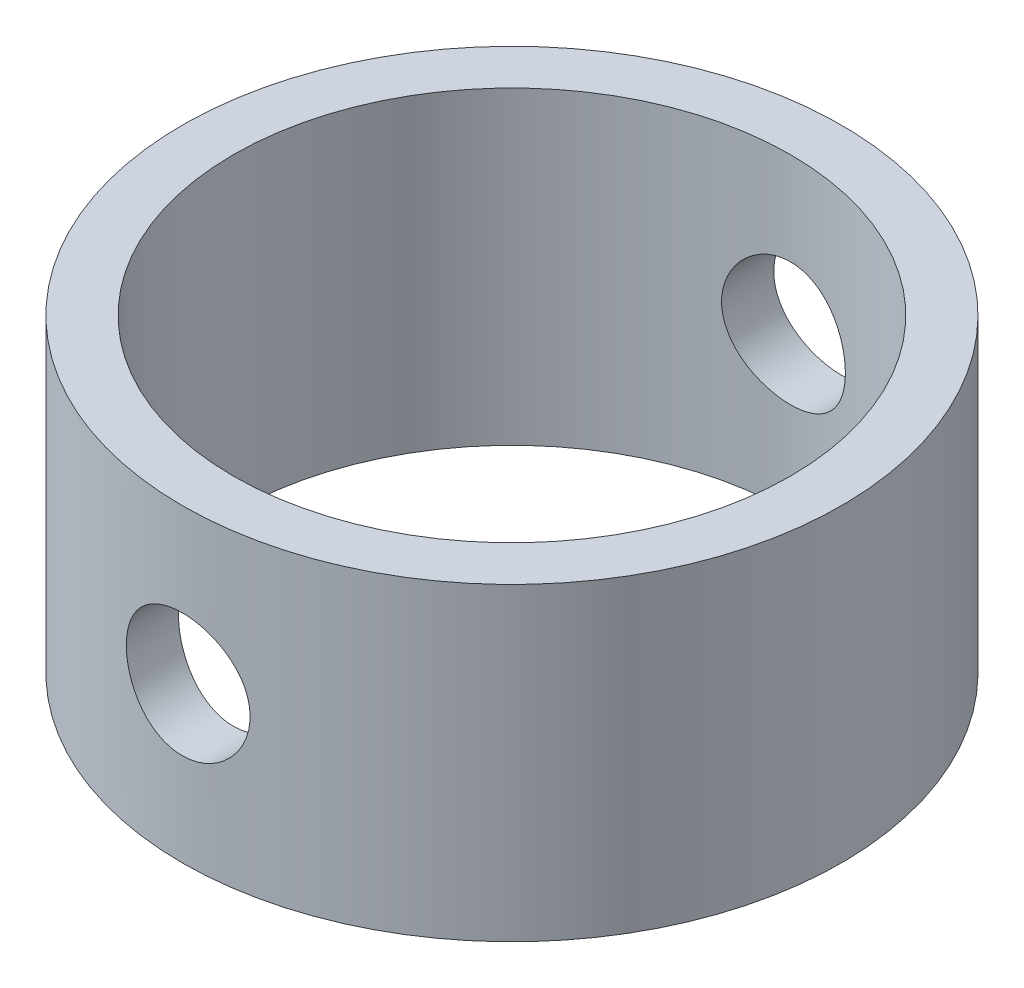
from build123d import *

# Parameters (mm, degrees)
BOSS_EXTRUDE1_DEPTH            = 12.7
BOSS_EXTRUDE1_DEPTH_BACK       = 12.7
SKETCH1_R                      = 27.051
SKETCH1_R_2                    = 22.86
CUT_EXTRUDE1_REACH             = 42.309
SKETCH2_R                      = 5.08
CUT_EXTRUDE1_DIRECTION_2_REACH = 42.309


with BuildPart() as part:
    # Sketch1 → Boss-Extrude1 (new, two sides: drawn at the far end of the back side and taken through both)
    with BuildSketch(Plane(origin=(0, 0, 0), x_dir=(1, 0, 0), z_dir=(0, 1, 0)).offset(-BOSS_EXTRUDE1_DEPTH_BACK)):
        Circle(SKETCH1_R)
        Circle(SKETCH1_R_2, mode=Mode.SUBTRACT)
    extrude(amount=BOSS_EXTRUDE1_DEPTH + BOSS_EXTRUDE1_DEPTH_BACK)

    # Sketch2 → Cut-Extrude1 (cut, up to next)
    with BuildSketch(Plane.XY, mode=Mode.PRIVATE) as cut_extrude1_sk1:
        Circle(SKETCH2_R)
    cut_extrude1_tool1 = extrude(cut_extrude1_sk1.sketch, amount=-CUT_EXTRUDE1_REACH, mode=Mode.PRIVATE) & part.part
    add(cut_extrude1_tool1.solids().sort_by_distance((0, 0, 0))[0], mode=Mode.SUBTRACT)

    # Sketch2 → Cut-Extrude1 direction 2 (cut, up to next)
    with BuildSketch(Plane.XY, mode=Mode.PRIVATE) as cut_extrude1_direction_2_sk1:
        Circle(SKETCH2_R)
    cut_extrude1_direction_2_tool1 = extrude(cut_extrude1_direction_2_sk1.sketch, amount=CUT_EXTRUDE1_DIRECTION_2_REACH, mode=Mode.PRIVATE) & part.part
    add(cut_extrude1_direction_2_tool1.solids().sort_by_distance((0, 0, 0))[0], mode=Mode.SUBTRACT)


solid = part.part
